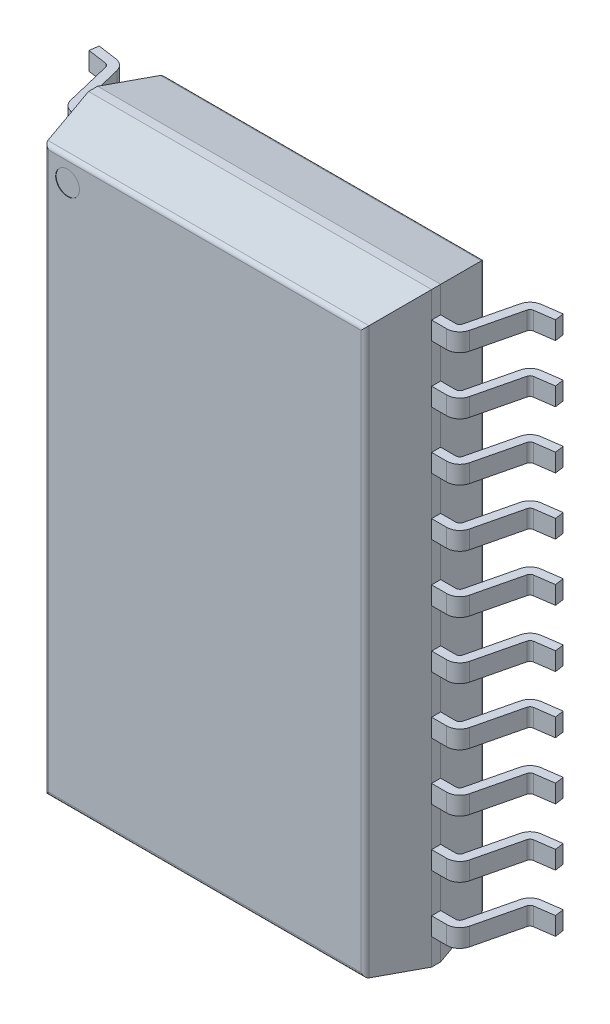
from build123d import *

# Parameters (mm, degrees)
SKETCH1_W                          = 7.6
SKETCH1_H                          = 13
BODY_DEPTH                         = 2.65
BODY_CHAMFER_SIZE                  = 1.225
BODY_CHAMFER_SIZE2                 = 0.260381788
BODY_CHAMFER_PART_2_SIZE           = 1.225
BODY_CHAMFER_PART_2_SIZE2          = 0.260381788
BODY_CHAMFER_PART_3_SIZE           = 1.225
BODY_CHAMFER_PART_3_SIZE2          = 0.260381788
BODY_CHAMFER_PART_4_SIZE           = 1.225
BODY_CHAMFER_PART_4_SIZE2          = 0.260381788
FILLET1_R                          = 0.1
SKETCH2_R                          = 0.263534387
PIN_1_INDENT_DEPTH                 = 0.01
PIN_DEPTH                          = 0.2
LPATTERN1_COUNT                    = 6
LPATTERN1_PITCH                    = 1.27
LPATTERN1_COL_COUNT                = 5
LPATTERN1_COL_PITCH                = 1.27
MIRROR1_COPY_1_DEPTH               = 0.2
MIRROR1_COPY_2_DEPTH               = 0.2
MIRROR1_COPY_3_DEPTH               = 0.2
MIRROR1_COPY_4_DEPTH               = 0.2
MIRROR1_COPY_5_DEPTH               = 0.2
MIRROR1_COPY_6_DEPTH               = 0.2
MIRROR1_COPY_7_DEPTH               = 0.2
MIRROR1_COPY_8_DEPTH               = 0.2
MIRROR1_COPY_9_DEPTH               = 0.2
K_RPER_VERSCHIEBEN_KOPIEREN1_ANGLE = 90


with BuildPart() as part:
    # Sketch1 → Body (new body)
    with BuildSketch(Plane(origin=(0, 0.15, 0), x_dir=(-1, 0, 0), z_dir=(0, 1, 0))):
        Rectangle(SKETCH1_W, SKETCH1_H)
    extrude(amount=BODY_DEPTH)

    # Body Chamfer
    body_chamfer_edges = [part.edges().sort_by_distance(p)[0] for p in [
        (3.8, 2.8, 0),
        (3.8, 0.15, 0),
    ]]
    body_chamfer_side = [part.faces().sort_by_distance(p)[0] for p in [
        (3.8, 1.475, 0),
    ]]
    chamfer(body_chamfer_edges, length=BODY_CHAMFER_SIZE, length2=BODY_CHAMFER_SIZE2, reference=body_chamfer_side[0])

    # Body Chamfer part 2
    body_chamfer_part_2_edges = [part.edges().sort_by_distance(p)[0] for p in [
        (0, 2.8, -6.5),
        (0, 0.15, -6.5),
    ]]
    body_chamfer_part_2_side = [part.faces().sort_by_distance(p)[0] for p in [
        (0, 1.475, -6.5),
    ]]
    chamfer(body_chamfer_part_2_edges, length=BODY_CHAMFER_PART_2_SIZE, length2=BODY_CHAMFER_PART_2_SIZE2, reference=body_chamfer_part_2_side[0])

    # Body Chamfer part 3
    body_chamfer_part_3_edges = [part.edges().sort_by_distance(p)[0] for p in [
        (-3.8, 2.8, 0),
        (-3.8, 0.15, 0),
    ]]
    body_chamfer_part_3_side = [part.faces().sort_by_distance(p)[0] for p in [
        (-3.8, 1.475, 0),
    ]]
    chamfer(body_chamfer_part_3_edges, length=BODY_CHAMFER_PART_3_SIZE, length2=BODY_CHAMFER_PART_3_SIZE2, reference=body_chamfer_part_3_side[0])

    # Body Chamfer part 4
    body_chamfer_part_4_edges = [part.edges().sort_by_distance(p)[0] for p in [
        (0, 0.15, 6.5),
        (0, 2.8, 6.5),
    ]]
    body_chamfer_part_4_side = [part.faces().sort_by_distance(p)[0] for p in [
        (0, 1.475, 6.5),
    ]]
    chamfer(body_chamfer_part_4_edges, length=BODY_CHAMFER_PART_4_SIZE, length2=BODY_CHAMFER_PART_4_SIZE2, reference=body_chamfer_part_4_side[0])

    # Fillet1
    fillet1_edges = [part.edges().sort_by_distance(p)[0] for p in [
        (-3.539618212, 0.15, 0),
        (0, 0.15, -6.239618212),
        (3.539618212, 0.15, 0),
        (0, 0.15, 6.239618212),
        (-3.539618212, 2.8, 0),
        (0, 2.8, 6.239618212),
        (3.539618212, 2.8, 0),
        (0, 2.8, -6.239618212),
    ]]
    fillet(fillet1_edges, radius=FILLET1_R)

    # Sketch2 → Pin #1 Indent (cut)
    with BuildSketch(Plane(origin=(0, 2.8, 0), x_dir=(1, 0, 0), z_dir=(0, 1, 0))):
        with Locations((-3.039618212, 5.739618212)):
            Circle(SKETCH2_R)
    extrude(amount=-PIN_1_INDENT_DEPTH, mode=Mode.SUBTRACT)

    # Sketch3 → Pin (add, symmetric)
    with BuildSketch(Plane.XY.offset(0.635)):
        with BuildLine():
            Line((-5.14, 0), (-4.711563027, 0.06021289))
            ThreePointArc((-4.711563027, 0.06021289), (-4.557038222, 0.132635339), (-4.47, 0.27942524))
            Line((-4.47, 0.27942524), (-4.222493415, 1.306092707))
            ThreePointArc((-4.222493415, 1.306092707), (-4.19068508, 1.355704822), (-4.135, 1.375))
            Line((-4.135, 1.375), (-3.8, 1.375))
            Line((-3.8, 1.375), (-3.8, 1.575))
            Line((-3.8, 1.575), (-4.135, 1.575))
            ThreePointArc((-4.135, 1.575), (-4.314429703, 1.512826648), (-4.416923227, 1.35296539))
            Line((-4.416923227, 1.35296539), (-4.664429812, 0.326297922))
            ThreePointArc((-4.664429812, 0.326297922), (-4.691441673, 0.280742436), (-4.739397648, 0.258266503))
            Line((-4.739397648, 0.258266503), (-5.16783462, 0.198053614))
            Line((-5.16783462, 0.198053614), (-5.14, 0))
        make_face()
    pin = extrude(amount=PIN_DEPTH, both=True)

    # LPattern1: Pin ×6
    with Locations(*[(0, 0, -i * LPATTERN1_PITCH) for i in range(1, LPATTERN1_COUNT)]):
        add(pin)

    # LPattern1 col: Pin ×5
    with Locations(*[(0, 0, i * LPATTERN1_COL_PITCH) for i in range(1, LPATTERN1_COL_COUNT)]):
        add(pin)

    # Mirror1: Pin across plane
    add(pin.mirror(Plane(origin=(0, 0, 0), x_dir=(0, 0, 1), z_dir=(1, 0, 0))))

    # Mirror1 copy 1 sketch → Mirror1 copy 1 (add, symmetric)
    with BuildSketch(Plane(origin=(0, 0, -0.635), x_dir=(-1, 0, 0), z_dir=(0, 0, 1))):
        with BuildLine():
            Line((-5.14, 0), (-4.711563027, -0.06021289))
            ThreePointArc((-4.711563027, -0.06021289), (-4.557038222, -0.132635339), (-4.47, -0.27942524))
            Line((-4.47, -0.27942524), (-4.222493415, -1.306092707))
            ThreePointArc((-4.222493415, -1.306092707), (-4.19068508, -1.355704822), (-4.135, -1.375))
            Line((-4.135, -1.375), (-3.8, -1.375))
            Line((-3.8, -1.375), (-3.8, -1.575))
            Line((-3.8, -1.575), (-4.135, -1.575))
            ThreePointArc((-4.135, -1.575), (-4.314429703, -1.512826648), (-4.416923227, -1.35296539))
            Line((-4.416923227, -1.35296539), (-4.664429812, -0.326297922))
            ThreePointArc((-4.664429812, -0.326297922), (-4.691441673, -0.280742436), (-4.739397648, -0.258266503))
            Line((-4.739397648, -0.258266503), (-5.16783462, -0.198053614))
            Line((-5.16783462, -0.198053614), (-5.14, 0))
        make_face()
    extrude(amount=MIRROR1_COPY_1_DEPTH, both=True)

    # Mirror1 copy 2 sketch → Mirror1 copy 2 (add, symmetric)
    with BuildSketch(Plane(origin=(0, 0, -1.905), x_dir=(-1, 0, 0), z_dir=(0, 0, 1))):
        with BuildLine():
            Line((-5.14, 0), (-4.711563027, -0.06021289))
            ThreePointArc((-4.711563027, -0.06021289), (-4.557038222, -0.132635339), (-4.47, -0.27942524))
            Line((-4.47, -0.27942524), (-4.222493415, -1.306092707))
            ThreePointArc((-4.222493415, -1.306092707), (-4.19068508, -1.355704822), (-4.135, -1.375))
            Line((-4.135, -1.375), (-3.8, -1.375))
            Line((-3.8, -1.375), (-3.8, -1.575))
            Line((-3.8, -1.575), (-4.135, -1.575))
            ThreePointArc((-4.135, -1.575), (-4.314429703, -1.512826648), (-4.416923227, -1.35296539))
            Line((-4.416923227, -1.35296539), (-4.664429812, -0.326297922))
            ThreePointArc((-4.664429812, -0.326297922), (-4.691441673, -0.280742436), (-4.739397648, -0.258266503))
            Line((-4.739397648, -0.258266503), (-5.16783462, -0.198053614))
            Line((-5.16783462, -0.198053614), (-5.14, 0))
        make_face()
    extrude(amount=MIRROR1_COPY_2_DEPTH, both=True)

    # Mirror1 copy 3 sketch → Mirror1 copy 3 (add, symmetric)
    with BuildSketch(Plane(origin=(0, 0, -3.175), x_dir=(-1, 0, 0), z_dir=(0, 0, 1))):
        with BuildLine():
            Line((-5.14, 0), (-4.711563027, -0.06021289))
            ThreePointArc((-4.711563027, -0.06021289), (-4.557038222, -0.132635339), (-4.47, -0.27942524))
            Line((-4.47, -0.27942524), (-4.222493415, -1.306092707))
            ThreePointArc((-4.222493415, -1.306092707), (-4.19068508, -1.355704822), (-4.135, -1.375))
            Line((-4.135, -1.375), (-3.8, -1.375))
            Line((-3.8, -1.375), (-3.8, -1.575))
            Line((-3.8, -1.575), (-4.135, -1.575))
            ThreePointArc((-4.135, -1.575), (-4.314429703, -1.512826648), (-4.416923227, -1.35296539))
            Line((-4.416923227, -1.35296539), (-4.664429812, -0.326297922))
            ThreePointArc((-4.664429812, -0.326297922), (-4.691441673, -0.280742436), (-4.739397648, -0.258266503))
            Line((-4.739397648, -0.258266503), (-5.16783462, -0.198053614))
            Line((-5.16783462, -0.198053614), (-5.14, 0))
        make_face()
    extrude(amount=MIRROR1_COPY_3_DEPTH, both=True)

    # Mirror1 copy 4 sketch → Mirror1 copy 4 (add, symmetric)
    with BuildSketch(Plane(origin=(0, 0, -4.445), x_dir=(-1, 0, 0), z_dir=(0, 0, 1))):
        with BuildLine():
            Line((-5.14, 0), (-4.711563027, -0.06021289))
            ThreePointArc((-4.711563027, -0.06021289), (-4.557038222, -0.132635339), (-4.47, -0.27942524))
            Line((-4.47, -0.27942524), (-4.222493415, -1.306092707))
            ThreePointArc((-4.222493415, -1.306092707), (-4.19068508, -1.355704822), (-4.135, -1.375))
            Line((-4.135, -1.375), (-3.8, -1.375))
            Line((-3.8, -1.375), (-3.8, -1.575))
            Line((-3.8, -1.575), (-4.135, -1.575))
            ThreePointArc((-4.135, -1.575), (-4.314429703, -1.512826648), (-4.416923227, -1.35296539))
            Line((-4.416923227, -1.35296539), (-4.664429812, -0.326297922))
            ThreePointArc((-4.664429812, -0.326297922), (-4.691441673, -0.280742436), (-4.739397648, -0.258266503))
            Line((-4.739397648, -0.258266503), (-5.16783462, -0.198053614))
            Line((-5.16783462, -0.198053614), (-5.14, 0))
        make_face()
    extrude(amount=MIRROR1_COPY_4_DEPTH, both=True)

    # Mirror1 copy 5 sketch → Mirror1 copy 5 (add, symmetric)
    with BuildSketch(Plane(origin=(0, 0, -5.715), x_dir=(-1, 0, 0), z_dir=(0, 0, 1))):
        with BuildLine():
            Line((-5.14, 0), (-4.711563027, -0.06021289))
            ThreePointArc((-4.711563027, -0.06021289), (-4.557038222, -0.132635339), (-4.47, -0.27942524))
            Line((-4.47, -0.27942524), (-4.222493415, -1.306092707))
            ThreePointArc((-4.222493415, -1.306092707), (-4.19068508, -1.355704822), (-4.135, -1.375))
            Line((-4.135, -1.375), (-3.8, -1.375))
            Line((-3.8, -1.375), (-3.8, -1.575))
            Line((-3.8, -1.575), (-4.135, -1.575))
            ThreePointArc((-4.135, -1.575), (-4.314429703, -1.512826648), (-4.416923227, -1.35296539))
            Line((-4.416923227, -1.35296539), (-4.664429812, -0.326297922))
            ThreePointArc((-4.664429812, -0.326297922), (-4.691441673, -0.280742436), (-4.739397648, -0.258266503))
            Line((-4.739397648, -0.258266503), (-5.16783462, -0.198053614))
            Line((-5.16783462, -0.198053614), (-5.14, 0))
        make_face()
    extrude(amount=MIRROR1_COPY_5_DEPTH, both=True)

    # Mirror1 copy 6 sketch → Mirror1 copy 6 (add, symmetric)
    with BuildSketch(Plane(origin=(0, 0, 1.905), x_dir=(-1, 0, 0), z_dir=(0, 0, 1))):
        with BuildLine():
            Line((-5.14, 0), (-4.711563027, -0.06021289))
            ThreePointArc((-4.711563027, -0.06021289), (-4.557038222, -0.132635339), (-4.47, -0.27942524))
            Line((-4.47, -0.27942524), (-4.222493415, -1.306092707))
            ThreePointArc((-4.222493415, -1.306092707), (-4.19068508, -1.355704822), (-4.135, -1.375))
            Line((-4.135, -1.375), (-3.8, -1.375))
            Line((-3.8, -1.375), (-3.8, -1.575))
            Line((-3.8, -1.575), (-4.135, -1.575))
            ThreePointArc((-4.135, -1.575), (-4.314429703, -1.512826648), (-4.416923227, -1.35296539))
            Line((-4.416923227, -1.35296539), (-4.664429812, -0.326297922))
            ThreePointArc((-4.664429812, -0.326297922), (-4.691441673, -0.280742436), (-4.739397648, -0.258266503))
            Line((-4.739397648, -0.258266503), (-5.16783462, -0.198053614))
            Line((-5.16783462, -0.198053614), (-5.14, 0))
        make_face()
    extrude(amount=MIRROR1_COPY_6_DEPTH, both=True)

    # Mirror1 copy 7 sketch → Mirror1 copy 7 (add, symmetric)
    with BuildSketch(Plane(origin=(0, 0, 3.175), x_dir=(-1, 0, 0), z_dir=(0, 0, 1))):
        with BuildLine():
            Line((-5.14, 0), (-4.711563027, -0.06021289))
            ThreePointArc((-4.711563027, -0.06021289), (-4.557038222, -0.132635339), (-4.47, -0.27942524))
            Line((-4.47, -0.27942524), (-4.222493415, -1.306092707))
            ThreePointArc((-4.222493415, -1.306092707), (-4.19068508, -1.355704822), (-4.135, -1.375))
            Line((-4.135, -1.375), (-3.8, -1.375))
            Line((-3.8, -1.375), (-3.8, -1.575))
            Line((-3.8, -1.575), (-4.135, -1.575))
            ThreePointArc((-4.135, -1.575), (-4.314429703, -1.512826648), (-4.416923227, -1.35296539))
            Line((-4.416923227, -1.35296539), (-4.664429812, -0.326297922))
            ThreePointArc((-4.664429812, -0.326297922), (-4.691441673, -0.280742436), (-4.739397648, -0.258266503))
            Line((-4.739397648, -0.258266503), (-5.16783462, -0.198053614))
            Line((-5.16783462, -0.198053614), (-5.14, 0))
        make_face()
    extrude(amount=MIRROR1_COPY_7_DEPTH, both=True)

    # Mirror1 copy 8 sketch → Mirror1 copy 8 (add, symmetric)
    with BuildSketch(Plane(origin=(0, 0, 4.445), x_dir=(-1, 0, 0), z_dir=(0, 0, 1))):
        with BuildLine():
            Line((-5.14, 0), (-4.711563027, -0.06021289))
            ThreePointArc((-4.711563027, -0.06021289), (-4.557038222, -0.132635339), (-4.47, -0.27942524))
            Line((-4.47, -0.27942524), (-4.222493415, -1.306092707))
            ThreePointArc((-4.222493415, -1.306092707), (-4.19068508, -1.355704822), (-4.135, -1.375))
            Line((-4.135, -1.375), (-3.8, -1.375))
            Line((-3.8, -1.375), (-3.8, -1.575))
            Line((-3.8, -1.575), (-4.135, -1.575))
            ThreePointArc((-4.135, -1.575), (-4.314429703, -1.512826648), (-4.416923227, -1.35296539))
            Line((-4.416923227, -1.35296539), (-4.664429812, -0.326297922))
            ThreePointArc((-4.664429812, -0.326297922), (-4.691441673, -0.280742436), (-4.739397648, -0.258266503))
            Line((-4.739397648, -0.258266503), (-5.16783462, -0.198053614))
            Line((-5.16783462, -0.198053614), (-5.14, 0))
        make_face()
    extrude(amount=MIRROR1_COPY_8_DEPTH, both=True)

    # Mirror1 copy 9 sketch → Mirror1 copy 9 (add, symmetric)
    with BuildSketch(Plane(origin=(0, 0, 5.715), x_dir=(-1, 0, 0), z_dir=(0, 0, 1))):
        with BuildLine():
            Line((-5.14, 0), (-4.711563027, -0.06021289))
            ThreePointArc((-4.711563027, -0.06021289), (-4.557038222, -0.132635339), (-4.47, -0.27942524))
            Line((-4.47, -0.27942524), (-4.222493415, -1.306092707))
            ThreePointArc((-4.222493415, -1.306092707), (-4.19068508, -1.355704822), (-4.135, -1.375))
            Line((-4.135, -1.375), (-3.8, -1.375))
            Line((-3.8, -1.375), (-3.8, -1.575))
            Line((-3.8, -1.575), (-4.135, -1.575))
            ThreePointArc((-4.135, -1.575), (-4.314429703, -1.512826648), (-4.416923227, -1.35296539))
            Line((-4.416923227, -1.35296539), (-4.664429812, -0.326297922))
            ThreePointArc((-4.664429812, -0.326297922), (-4.691441673, -0.280742436), (-4.739397648, -0.258266503))
            Line((-4.739397648, -0.258266503), (-5.16783462, -0.198053614))
            Line((-5.16783462, -0.198053614), (-5.14, 0))
        make_face()
    extrude(amount=MIRROR1_COPY_9_DEPTH, both=True)


with BuildPart() as part_1:
    # Körper-Verschieben/Kopieren1: moved
    add(part.part.rotate(Axis((0, 0, 0), (1, 0, 0)), K_RPER_VERSCHIEBEN_KOPIEREN1_ANGLE))


solid = part_1.part
